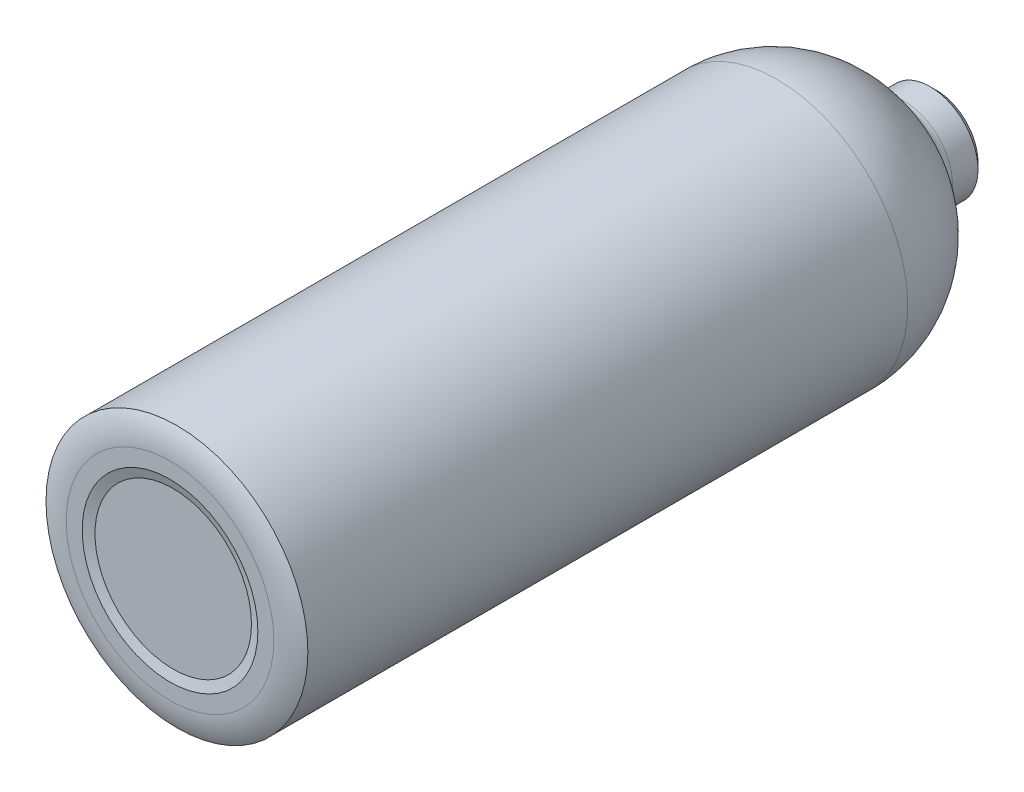
from build123d import *


with BuildPart() as part:
    # Sketch1 → Revolve1 (revolve)
    with BuildSketch(Plane(origin=(0, 0, 0), x_dir=(1, 0, 0), z_dir=(0, 1, 0))):
        with BuildLine():
            Line((-34, -46.163818636), (0, -46.163818636))
            Line((0, -46.163818636), (0, -52.268618281))
            Line((0, -52.268618281), (-24.5, -52.268618281))
            Line((-24.5, -52.268618281), (-27.5, -53.268618281))
            Line((-27.5, -53.268618281), (-32.5, -53.268618281))
            ThreePointArc((-32.5, -53.268618281), (-36.885372769, -52.719543337), (-41, -51.106217468))
            Line((-41, -51.106217468), (-41, 136.731381719))
            ThreePointArc((-41, 136.731381719), (-34.81270119, 157.603387492), (-18.25, 171.731381719))
            ThreePointArc((-18.25, 171.731381719), (-15.88389983, 173.749666608), (-15, 176.731381719))
            Line((-15, 176.731381719), (-15, 184.731381719))
            Line((-15, 184.731381719), (-13, 186.731381719))
            Line((-13, 186.731381719), (-8, 186.731381719))
            Line((-8, 186.731381719), (-8, 179.731381719))
            Line((-8, 179.731381719), (-8, 176.731381719))
            ThreePointArc((-8, 176.731381719), (-10.014794516, 169.934748154), (-15.408172232, 165.33419367))
            ThreePointArc((-15.408172232, 165.33419367), (-28.943595876, 153.788469038), (-34, 136.731381719))
            Line((-34, 136.731381719), (-34, -46.163818636))
        make_face()
    revolve(axis=Axis((0, 0, 52.268618281), (0, 0, -1)))


solid = part.part
